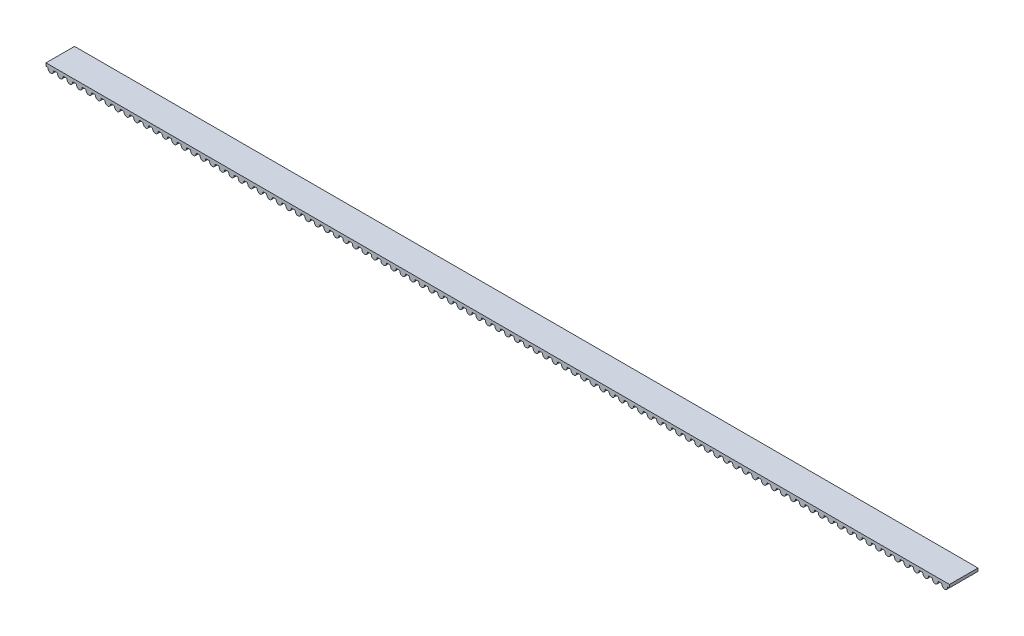
from build123d import *

# Parameters (mm, degrees)
BOSS_EXTRUDE1_DEPTH = 6
LPATTERN2_COUNT     = 14
LPATTERN2_PITCH     = 10


with BuildPart() as part:
    # Sketch1 → Boss-Extrude1 (new body)
    with BuildSketch(Plane.XY):
        with BuildLine():
            Line((0, 0), (30, 0))
            Line((30, 0), (30, -0.63))
            Line((30, -0.63), (29.738903282, -0.63))
            ThreePointArc((29.738903282, -0.63), (29.639817638, -0.667385458), (29.590123489, -0.760906198))
            ThreePointArc((29.590123489, -0.760906198), (29.55760715, -0.915836794), (29.501048757, -1.063694665))
            ThreePointArc((29.501048757, -1.063694665), (29, -1.38), (28.498951243, -1.063694665))
            ThreePointArc((28.498951243, -1.063694665), (28.44239285, -0.915836794), (28.409876511, -0.760906198))
            ThreePointArc((28.409876511, -0.760906198), (28.360182362, -0.667385458), (28.261096718, -0.63))
            Line((28.261096718, -0.63), (28, -0.63))
            Line((28, -0.63), (27.738903282, -0.63))
            ThreePointArc((27.738903282, -0.63), (27.639817638, -0.667385458), (27.590123489, -0.760906198))
            ThreePointArc((27.590123489, -0.760906198), (27.55760715, -0.915836794), (27.501048757, -1.063694665))
            ThreePointArc((27.501048757, -1.063694665), (27, -1.38), (26.498951243, -1.063694665))
            ThreePointArc((26.498951243, -1.063694665), (26.44239285, -0.915836794), (26.409876511, -0.760906198))
            ThreePointArc((26.409876511, -0.760906198), (26.360182362, -0.667385458), (26.261096718, -0.63))
            Line((26.261096718, -0.63), (26, -0.63))
            Line((26, -0.63), (25.738903282, -0.63))
            ThreePointArc((25.738903282, -0.63), (25.639817638, -0.667385458), (25.590123489, -0.760906198))
            ThreePointArc((25.590123489, -0.760906198), (25.55760715, -0.915836794), (25.501048757, -1.063694665))
            ThreePointArc((25.501048757, -1.063694665), (25, -1.38), (24.498951243, -1.063694665))
            ThreePointArc((24.498951243, -1.063694665), (24.44239285, -0.915836794), (24.409876511, -0.760906198))
            ThreePointArc((24.409876511, -0.760906198), (24.360182362, -0.667385458), (24.261096718, -0.63))
            Line((24.261096718, -0.63), (24, -0.63))
            Line((24, -0.63), (23.738903282, -0.63))
            ThreePointArc((23.738903282, -0.63), (23.639817638, -0.667385458), (23.590123489, -0.760906198))
            ThreePointArc((23.590123489, -0.760906198), (23.55760715, -0.915836794), (23.501048757, -1.063694665))
            ThreePointArc((23.501048757, -1.063694665), (23, -1.38), (22.498951243, -1.063694665))
            ThreePointArc((22.498951243, -1.063694665), (22.44239285, -0.915836794), (22.409876511, -0.760906198))
            ThreePointArc((22.409876511, -0.760906198), (22.360182362, -0.667385458), (22.261096718, -0.63))
            Line((22.261096718, -0.63), (22, -0.63))
            Line((22, -0.63), (21.738903282, -0.63))
            ThreePointArc((21.738903282, -0.63), (21.639817638, -0.667385458), (21.590123489, -0.760906198))
            ThreePointArc((21.590123489, -0.760906198), (21.55760715, -0.915836794), (21.501048757, -1.063694665))
            ThreePointArc((21.501048757, -1.063694665), (21, -1.38), (20.498951243, -1.063694665))
            ThreePointArc((20.498951243, -1.063694665), (20.44239285, -0.915836794), (20.409876511, -0.760906198))
            ThreePointArc((20.409876511, -0.760906198), (20.360182362, -0.667385458), (20.261096718, -0.63))
            Line((20.261096718, -0.63), (20, -0.63))
            Line((20, -0.63), (19.738903282, -0.63))
            ThreePointArc((19.738903282, -0.63), (19.639817638, -0.667385458), (19.590123489, -0.760906198))
            ThreePointArc((19.590123489, -0.760906198), (19.55760715, -0.915836794), (19.501048757, -1.063694665))
            ThreePointArc((19.501048757, -1.063694665), (19, -1.38), (18.498951243, -1.063694665))
            ThreePointArc((18.498951243, -1.063694665), (18.44239285, -0.915836794), (18.409876511, -0.760906198))
            ThreePointArc((18.409876511, -0.760906198), (18.360182362, -0.667385458), (18.261096718, -0.63))
            Line((18.261096718, -0.63), (18, -0.63))
            Line((18, -0.63), (17.738903282, -0.63))
            ThreePointArc((17.738903282, -0.63), (17.639817638, -0.667385458), (17.590123489, -0.760906198))
            ThreePointArc((17.590123489, -0.760906198), (17.55760715, -0.915836794), (17.501048757, -1.063694665))
            ThreePointArc((17.501048757, -1.063694665), (17, -1.38), (16.498951243, -1.063694665))
            ThreePointArc((16.498951243, -1.063694665), (16.44239285, -0.915836794), (16.409876511, -0.760906198))
            ThreePointArc((16.409876511, -0.760906198), (16.360182362, -0.667385458), (16.261096718, -0.63))
            Line((16.261096718, -0.63), (16, -0.63))
            Line((16, -0.63), (15.738903282, -0.63))
            ThreePointArc((15.738903282, -0.63), (15.639817638, -0.667385458), (15.590123489, -0.760906198))
            ThreePointArc((15.590123489, -0.760906198), (15.55760715, -0.915836794), (15.501048757, -1.063694665))
            ThreePointArc((15.501048757, -1.063694665), (15, -1.38), (14.498951243, -1.063694665))
            ThreePointArc((14.498951243, -1.063694665), (14.44239285, -0.915836794), (14.409876511, -0.760906198))
            ThreePointArc((14.409876511, -0.760906198), (14.360182362, -0.667385458), (14.261096718, -0.63))
            Line((14.261096718, -0.63), (14, -0.63))
            Line((14, -0.63), (13.738903282, -0.63))
            ThreePointArc((13.738903282, -0.63), (13.639817638, -0.667385458), (13.590123489, -0.760906198))
            ThreePointArc((13.590123489, -0.760906198), (13.55760715, -0.915836794), (13.501048757, -1.063694665))
            ThreePointArc((13.501048757, -1.063694665), (13, -1.38), (12.498951243, -1.063694665))
            ThreePointArc((12.498951243, -1.063694665), (12.44239285, -0.915836794), (12.409876511, -0.760906198))
            ThreePointArc((12.409876511, -0.760906198), (12.360182362, -0.667385458), (12.261096718, -0.63))
            Line((12.261096718, -0.63), (12, -0.63))
            Line((12, -0.63), (11.738903282, -0.63))
            ThreePointArc((11.738903282, -0.63), (11.639817638, -0.667385458), (11.590123489, -0.760906198))
            ThreePointArc((11.590123489, -0.760906198), (11.55760715, -0.915836794), (11.501048757, -1.063694665))
            ThreePointArc((11.501048757, -1.063694665), (11, -1.38), (10.498951243, -1.063694665))
            ThreePointArc((10.498951243, -1.063694665), (10.44239285, -0.915836794), (10.409876511, -0.760906198))
            ThreePointArc((10.409876511, -0.760906198), (10.360182362, -0.667385458), (10.261096718, -0.63))
            Line((10.261096718, -0.63), (10, -0.63))
            Line((10, -0.63), (9.738903282, -0.63))
            ThreePointArc((9.738903282, -0.63), (9.639817638, -0.667385458), (9.590123489, -0.760906198))
            ThreePointArc((9.590123489, -0.760906198), (9.55760715, -0.915836794), (9.501048757, -1.063694665))
            ThreePointArc((9.501048757, -1.063694665), (9, -1.38), (8.498951243, -1.063694665))
            ThreePointArc((8.498951243, -1.063694665), (8.44239285, -0.915836794), (8.409876511, -0.760906198))
            ThreePointArc((8.409876511, -0.760906198), (8.360182362, -0.667385458), (8.261096718, -0.63))
            Line((8.261096718, -0.63), (8, -0.63))
            Line((8, -0.63), (7.738903282, -0.63))
            ThreePointArc((7.738903282, -0.63), (7.639817638, -0.667385458), (7.590123489, -0.760906198))
            ThreePointArc((7.590123489, -0.760906198), (7.55760715, -0.915836794), (7.501048757, -1.063694665))
            ThreePointArc((7.501048757, -1.063694665), (7, -1.38), (6.498951243, -1.063694665))
            ThreePointArc((6.498951243, -1.063694665), (6.44239285, -0.915836794), (6.409876511, -0.760906198))
            ThreePointArc((6.409876511, -0.760906198), (6.360182362, -0.667385458), (6.261096718, -0.63))
            Line((6.261096718, -0.63), (6, -0.63))
            Line((6, -0.63), (5.738903282, -0.63))
            ThreePointArc((5.738903282, -0.63), (5.639817638, -0.667385458), (5.590123489, -0.760906198))
            ThreePointArc((5.590123489, -0.760906198), (5.55760715, -0.915836794), (5.501048757, -1.063694665))
            ThreePointArc((5.501048757, -1.063694665), (5, -1.38), (4.498951243, -1.063694665))
            ThreePointArc((4.498951243, -1.063694665), (4.44239285, -0.915836794), (4.409876511, -0.760906198))
            ThreePointArc((4.409876511, -0.760906198), (4.360182362, -0.667385458), (4.261096718, -0.63))
            Line((4.261096718, -0.63), (4, -0.63))
            Line((4, -0.63), (3.738903282, -0.63))
            ThreePointArc((3.738903282, -0.63), (3.639817638, -0.667385458), (3.590123489, -0.760906198))
            ThreePointArc((3.590123489, -0.760906198), (3.55760715, -0.915836794), (3.501048757, -1.063694665))
            ThreePointArc((3.501048757, -1.063694665), (3, -1.38), (2.498951243, -1.063694665))
            ThreePointArc((2.498951243, -1.063694665), (2.44239285, -0.915836794), (2.409876511, -0.760906198))
            ThreePointArc((2.409876511, -0.760906198), (2.360182362, -0.667385458), (2.261096718, -0.63))
            Line((2.261096718, -0.63), (2, -0.63))
            Line((2, -0.63), (1.738903282, -0.63))
            ThreePointArc((1.738903282, -0.63), (1.639817638, -0.667385458), (1.590123489, -0.760906198))
            ThreePointArc((1.590123489, -0.760906198), (1.55760715, -0.915836794), (1.501048757, -1.063694665))
            ThreePointArc((1.501048757, -1.063694665), (1, -1.38), (0.498951243, -1.063694665))
            ThreePointArc((0.498951243, -1.063694665), (0.44239285, -0.915836794), (0.409876511, -0.760906198))
            ThreePointArc((0.409876511, -0.760906198), (0.360182362, -0.667385458), (0.261096718, -0.63))
            Line((0.261096718, -0.63), (0, -0.63))
            Line((0, -0.63), (0, 0))
        make_face()
    boss_extrude1 = extrude(amount=BOSS_EXTRUDE1_DEPTH)

    # Mirror1: Boss-Extrude1 across plane
    add(boss_extrude1.mirror(Plane(origin=(30, 0, 6), x_dir=(0, 0, 1), z_dir=(1, 0, 0))))

    # LPattern2: Boss-Extrude1 ×14
    with Locations(*[(-i * LPATTERN2_PITCH, 0, 0) for i in range(1, LPATTERN2_COUNT)]):
        add(boss_extrude1)


solid = part.part
